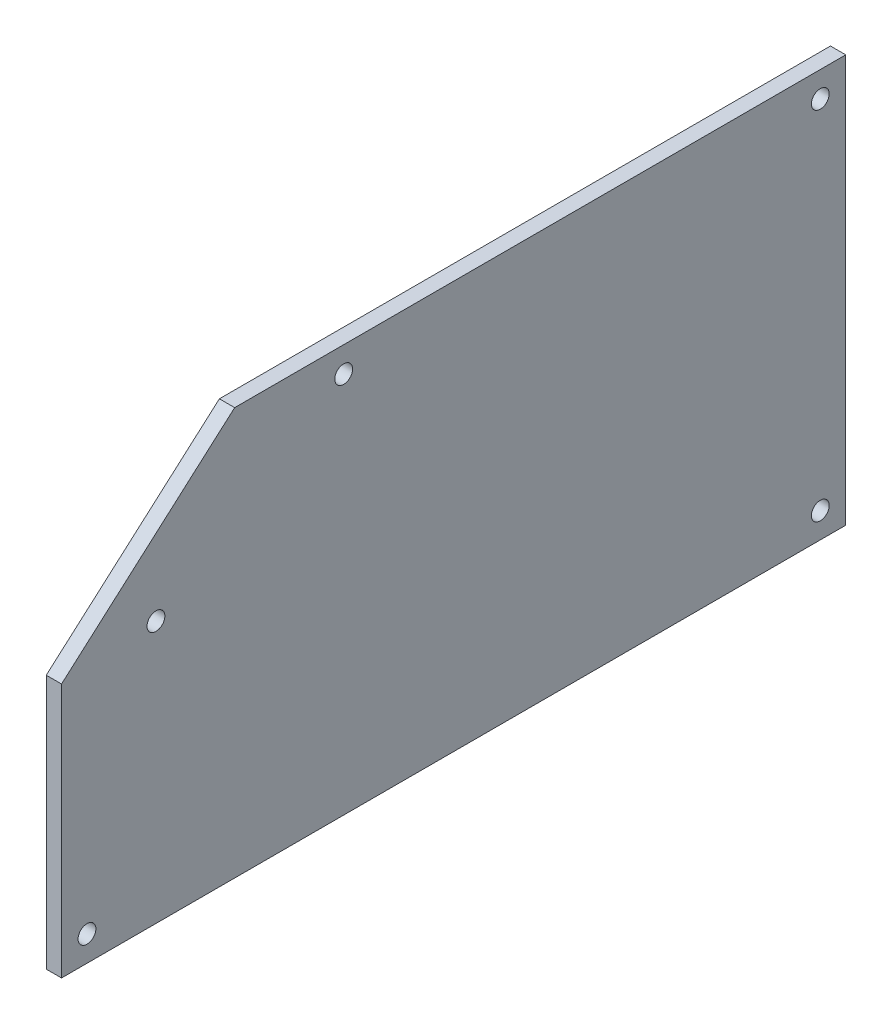
from build123d import *

# Parameters (mm, degrees)
BOSS_EXTRUDE1_DEPTH = 3
SKETCH2_R           = 1.75
CUT_EXTRUDE1_DEPTH  = 4


with BuildPart() as part:
    # Sketch1 → Boss-Extrude1 (new body)
    with BuildSketch(Plane(origin=(0, 0, 0), x_dir=(0, 0, -1), z_dir=(1, 0, 0))):
        Polygon((0, 0), (0, 50), (34, 80), (154, 80), (154, 0), align=None)
    extrude(amount=BOSS_EXTRUDE1_DEPTH)

    # Sketch2 → Cut-Extrude1 (cut, through all)
    with BuildSketch(Plane.ZY):
        with Locations((-149, 5)):
            Circle(SKETCH2_R)
        with Locations((-149, 75)):
            Circle(SKETCH2_R)
        with Locations((-5, 5)):
            Circle(SKETCH2_R)
        with Locations((-55.407189005, 75)):
            Circle(SKETCH2_R)
        with Locations((-18.540830268, 51.422993608)):
            Circle(SKETCH2_R)
    extrude(amount=-CUT_EXTRUDE1_DEPTH, mode=Mode.SUBTRACT)


solid = part.part
